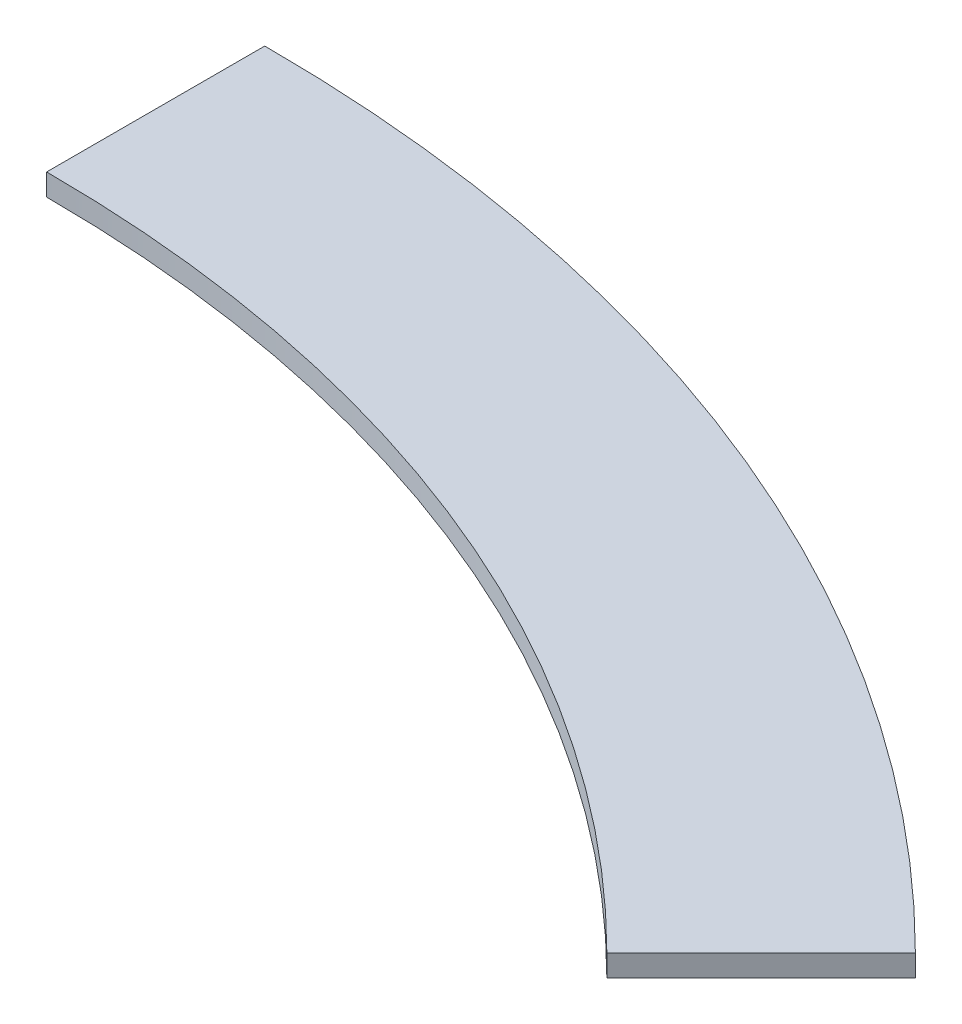
from build123d import *

# Parameters (mm, degrees)
BOSS_EXTRUDE1_DEPTH = 10


with BuildPart() as part:
    # Sketch1 → Boss-Extrude1 (new body)
    with BuildSketch(Plane(origin=(0, 0, 0), x_dir=(1, 0, 0), z_dir=(0, 1, 0))):
        with BuildLine():
            ThreePointArc((0, 720), (275.532071303, 665.193263408), (509.116882454, 509.116882454))
            Line((509.116882454, 509.116882454), (438.406204336, 438.406204336))
            ThreePointArc((438.406204336, 438.406204336), (237.263728066, 572.805310157), (0, 620))
            Line((0, 620), (0, 720))
        make_face()
    extrude(amount=BOSS_EXTRUDE1_DEPTH)


solid = part.part
